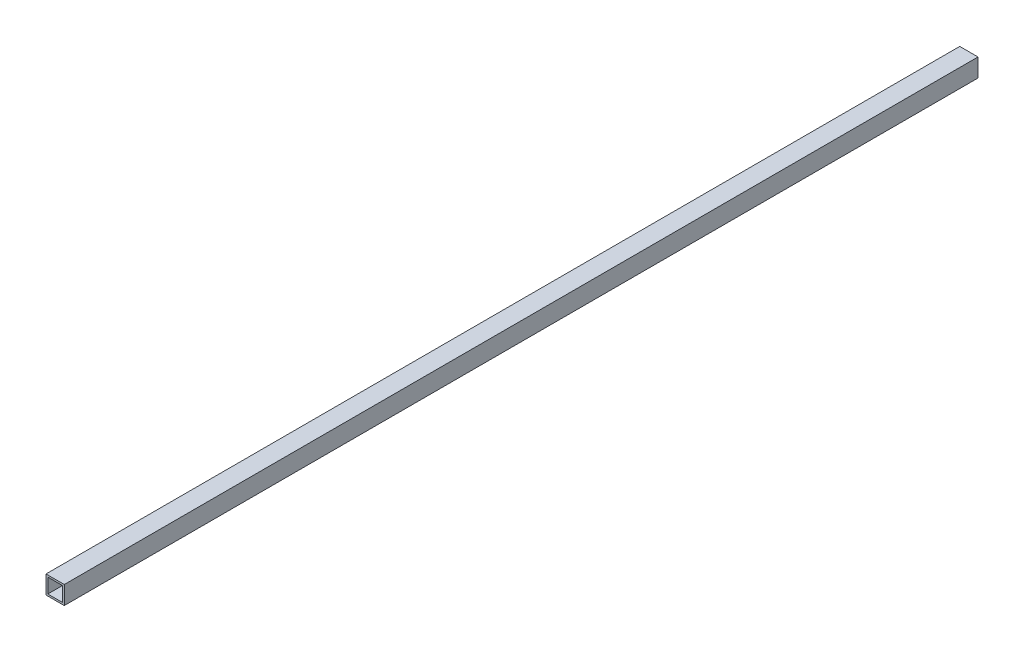
from build123d import *

# Parameters (mm, degrees)
IZIM1_W                     = 40
IZIM1_H                     = 40
IZIM1_W_2                   = 32
IZIM1_H_2                   = 32
Y_KSEKLIK_EKSTR_ZYON1_DEPTH = 2000


with BuildPart() as part:
    # Çizim1 → Yükseklik-Ekstrüzyon1 (new body)
    with BuildSketch(Plane.XY):
        with Locations((20, 20)):
            Rectangle(IZIM1_W, IZIM1_H)
        with Locations((20, 20)):
            Rectangle(IZIM1_W_2, IZIM1_H_2, mode=Mode.SUBTRACT)
    extrude(amount=-Y_KSEKLIK_EKSTR_ZYON1_DEPTH)


solid = part.part
